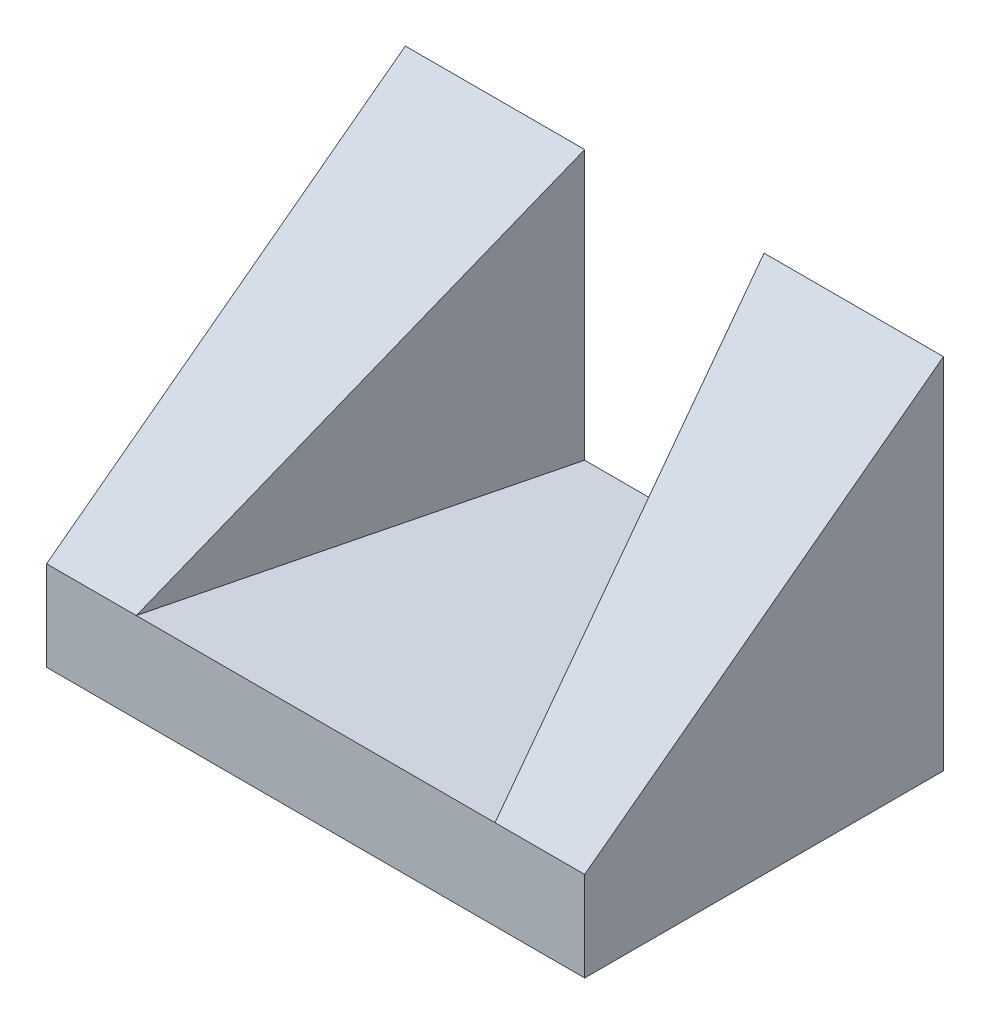
from build123d import *

# Parameters (mm, degrees)
CROQUIS1_W                 = 60
CROQUIS1_H                 = 40
SALIENTE_EXTRUIR1_DEPTH    = 10
SALIENTE_EXTRUIR2_DEPTH    = 30
CORTAR_EXTRUIR1_DEPTH      = 9
CORTAR_EXTRUIR1_DEPTH_BACK = 66


with BuildPart() as part:
    # Croquis1 → Saliente-Extruir1 (new body)
    with BuildSketch(Plane(origin=(0, 0, 0), x_dir=(1, 0, 0), z_dir=(0, 1, 0))):
        with Locations((30, 20)):
            Rectangle(CROQUIS1_W, CROQUIS1_H)
    extrude(amount=SALIENTE_EXTRUIR1_DEPTH)

    # Croquis2 → Saliente-Extruir2 (add)
    with BuildSketch(Plane(origin=(0, 10, 0), x_dir=(1, 0, 0), z_dir=(0, 1, 0))):
        Polygon((0, 0), (0, 40), (20, 40), (10, 0), align=None)
        Polygon((60, 40), (40, 40), (50, 0), (60, 0), align=None)
    extrude(amount=SALIENTE_EXTRUIR2_DEPTH)

    # Croquis3 → Cortar-Extruir1 (cut, two sides)
    with BuildSketch(Plane(origin=(60, 0, 0), x_dir=(0, 0, -1), z_dir=(1, 0, 0))) as cortar_extruir1_sk:
        Polygon((0, 40), (0, 10), (40, 40), align=None)
    extrude(amount=CORTAR_EXTRUIR1_DEPTH, mode=Mode.SUBTRACT)
    extrude(cortar_extruir1_sk.sketch, amount=-CORTAR_EXTRUIR1_DEPTH_BACK, mode=Mode.SUBTRACT)


solid = part.part
